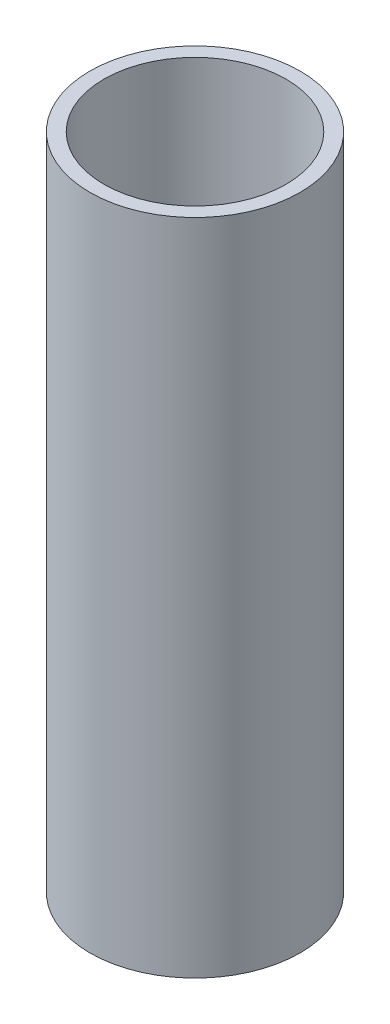
from build123d import *

# Parameters (mm, degrees)
SKETCH2_W = 2
SKETCH2_H = 94


with BuildPart() as part:
    # Sketch2 → Revolve2 (revolve)
    with BuildSketch(Plane.XY):
        with Locations((14, -47)):
            Rectangle(SKETCH2_W, SKETCH2_H)
    revolve(axis=Axis((0, 0, 0), (0, -1, 0)))


solid = part.part
